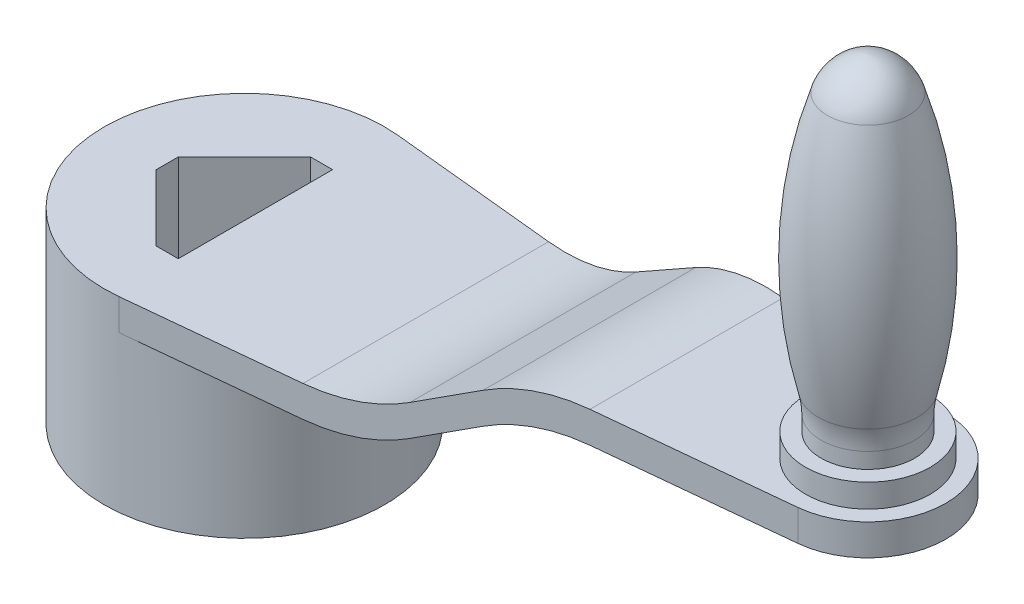
from build123d import *

# Parameters (mm, degrees)
IZIM2_R                     = 45
Y_KSEKLIK_EKSTR_ZYON1_DEPTH = 30
KES_EKSTR_ZYON1_DEPTH       = 61
Y_KSEKLIK_EKSTR_ZYON2_DEPTH = 45
KES_EKSTR_ZYON2_DEPTH       = 91
KES_EKSTR_ZYON4_DEPTH       = 1.428514546
IZIM10_R                    = 20
Y_KSEKLIK_EKSTR_ZYON3_DEPTH = 7.5


with BuildPart() as part:
    # Çizim2 → Yükseklik-Ekstrüzyon1 (new body, symmetric)
    with BuildSketch(Plane(origin=(0, 0, 0), x_dir=(1, 0, 0), z_dir=(0, 1, 0))):
        Circle(IZIM2_R)
    extrude(amount=Y_KSEKLIK_EKSTR_ZYON1_DEPTH, both=True)

    # Çizim3 → Kes-Ekstrüzyon1 (cut, through all)
    with BuildSketch(Plane(origin=(0, 30, 0), x_dir=(1, 0, 0), z_dir=(0, 1, 0))):
        Polygon((-24.748737342, 3.535533906), (-3.535533906, 24.748737342), (3.535533906, 24.748737342), (24.748737342, 3.535533906), (24.748737342, -3.535533906), (3.535533906, -24.748737342), (-3.535533906, -24.748737342), (-24.748737342, -3.535533906), align=None)
    extrude(amount=-KES_EKSTR_ZYON1_DEPTH, mode=Mode.SUBTRACT)

    # Çizim4 → Yükseklik-Ekstrüzyon2 (add, symmetric)
    with BuildSketch(Plane.XY):
        with BuildLine():
            Line((3.535533906, 30), (3.535533906, 20))
            Line((3.535533906, 20), (58.177999867, 20))
            ThreePointArc((58.177999867, 20), (74.375437748, 22.227662276), (89.370128252, 28.745233131))
            Line((89.370128252, 28.745233131), (110.629871748, 41.683281415))
            ThreePointArc((110.629871748, 41.683281415), (125.624562252, 48.20085227), (141.822000133, 50.428514546))
            Line((141.822000133, 50.428514546), (200, 50.428514546))
            Line((200, 50.428514546), (225, 50.428514546))
            Line((225, 50.428514546), (225, 60.428514546))
            Line((225, 60.428514546), (200, 60.428514546))
            Line((200, 60.428514546), (141.822000133, 60.428514546))
            ThreePointArc((141.822000133, 60.428514546), (125.624562252, 58.20085227), (110.629871748, 51.683281415))
            Line((110.629871748, 51.683281415), (89.370128252, 38.745233131))
            ThreePointArc((89.370128252, 38.745233131), (74.375437748, 32.227662276), (58.177999867, 30))
            Line((58.177999867, 30), (3.535533906, 30))
        make_face()
    extrude(amount=Y_KSEKLIK_EKSTR_ZYON2_DEPTH, both=True)

    # Çizim8 → Kes-Ekstrüzyon2 (cut, through all)
    with BuildSketch(Plane(origin=(0, 60, 0), x_dir=(1, 0, 0), z_dir=(0, 1, 0))):
        with BuildLine():
            ThreePointArc((3.535533906, 44.860896112), (4.017999525, 44.820259703), (4.5, 44.77443467))
            Line((4.5, 44.77443467), (202.5, 24.874685928))
            ThreePointArc((202.5, 24.874685928), (218.540496218, 16.770509831), (225, 0))
            Line((225, 0), (225, 45))
            Line((225, 45), (3.535533906, 45))
            Line((3.535533906, 45), (3.535533906, 44.860896112))
        make_face()
        with BuildLine():
            Line((225, -45), (225, 0))
            ThreePointArc((225, 0), (218.540496218, -16.770509831), (202.5, -24.874685928))
            Line((202.5, -24.874685928), (4.5, -44.77443467))
            ThreePointArc((4.5, -44.77443467), (4.017999525, -44.820259703), (3.535533906, -44.860896112))
            Line((3.535533906, -44.860896112), (3.535533906, -45))
            Line((3.535533906, -45), (225, -45))
        make_face()
    extrude(amount=-KES_EKSTR_ZYON2_DEPTH, mode=Mode.SUBTRACT)

    # Çizim9 → Kes-Ekstrüzyon4 (cut, through all)
    with BuildSketch(Plane(origin=(0, 60, 0), x_dir=(1, 0, 0), z_dir=(0, 1, 0))):
        with BuildLine():
            Line((134.663919329, 31.692468559), (202.5, 24.874685928))
            ThreePointArc((202.5, 24.874685928), (218.540496218, 16.770509831), (225, 0))
            Line((225, 0), (225, 45))
            Line((225, 45), (134.663919329, 45))
            Line((134.663919329, 45), (134.663919329, 31.692468559))
        make_face()
        with BuildLine():
            Line((202.5, -24.874685928), (134.663919329, -31.692468559))
            Line((134.663919329, -31.692468559), (134.663919329, -45))
            Line((134.663919329, -45), (225, -45))
            Line((225, -45), (225, 0))
            ThreePointArc((225, 0), (218.540496218, -16.770509831), (202.5, -24.874685928))
        make_face()
    extrude(amount=KES_EKSTR_ZYON4_DEPTH, mode=Mode.SUBTRACT)

    # Çizim10 → Yükseklik-Ekstrüzyon3 (add)
    with BuildSketch(Plane(origin=(0, 60.428514546, 0), x_dir=(1, 0, 0), z_dir=(0, 1, 0))):
        with Locations((200, 0)):
            Circle(IZIM10_R)
    extrude(amount=Y_KSEKLIK_EKSTR_ZYON3_DEPTH)

    # Çizim12 → Döndür1 (revolve)
    with BuildSketch(Plane.XY):
        with BuildLine():
            Line((185, 67.928514546), (185, 72.928514546))
            ThreePointArc((185, 72.928514546), (184.792317085, 76.332499126), (184.172349213, 79.685987317))
            ThreePointArc((184.172349213, 79.685987317), (179.829043862, 121.097612219), (187.037341752, 162.107701465))
            ThreePointArc((187.037341752, 162.107701465), (191.964278666, 169.220382002), (200, 172.428514546))
            Line((200, 172.428514546), (200, 67.928514546))
            Line((200, 67.928514546), (185, 67.928514546))
        make_face()
    revolve(axis=Axis((200, 67.928514546, 0), (0, 1, 0)))


solid = part.part
